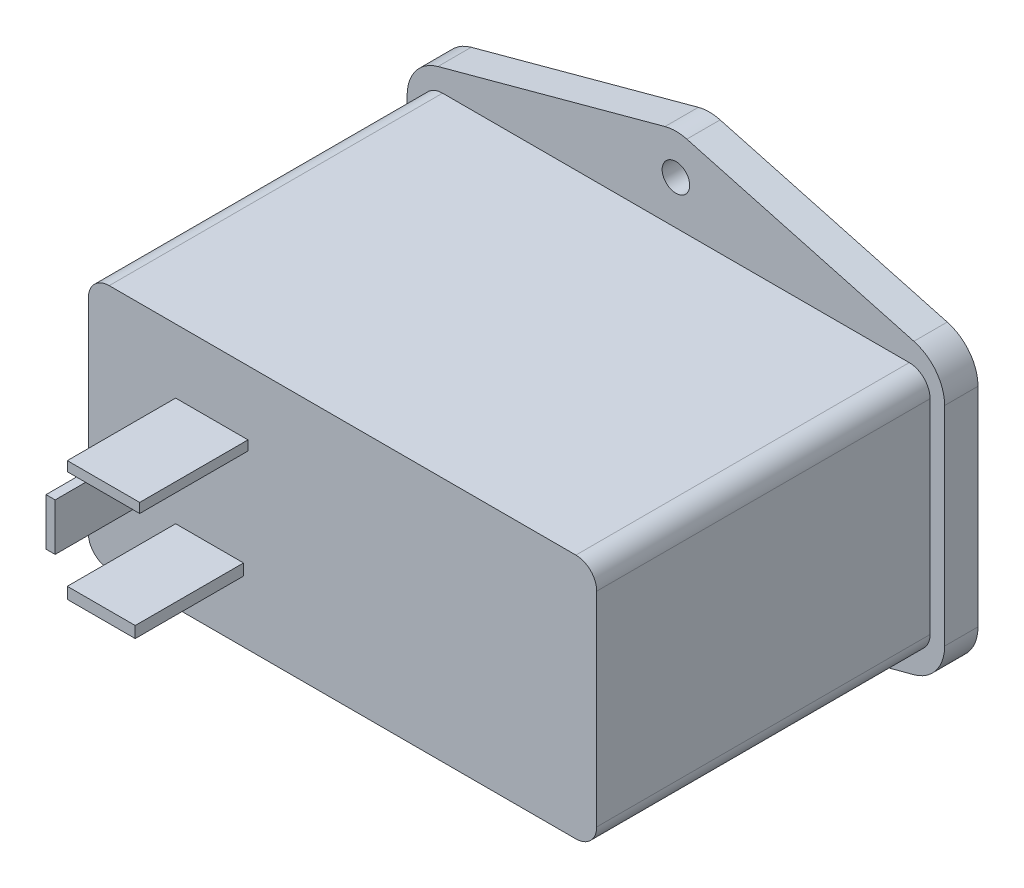
from build123d import *

# Parameters (mm, degrees)
BOSS_EXTRUDE1_DEPTH = 40
SKETCH2_R           = 1.65
BOSS_EXTRUDE2_DEPTH = 4
SKETCH3_W           = 1.094631416
SKETCH3_H           = 5.669527591
SKETCH3_W_2         = 8.149744195
SKETCH3_H_2         = 1.362465731
SKETCH3_W_3         = 8.685881664
SKETCH3_H_3         = 1.155421961
BOSS_EXTRUDE3_DEPTH = 13


with BuildPart() as part:
    # Sketch1 → Boss-Extrude1 (new body)
    with BuildSketch(Plane.XY):
        with BuildLine():
            Line((2.5, 0), (58.5, 0))
            ThreePointArc((58.5, 0), (60.267766953, 0.732233047), (61, 2.5))
            Line((61, 2.5), (61, 27))
            ThreePointArc((61, 27), (60.267766953, 28.767766953), (58.5, 29.5))
            Line((58.5, 29.5), (2.5, 29.5))
            ThreePointArc((2.5, 29.5), (0.732233047, 28.767766953), (0, 27))
            Line((0, 27), (0, 2.5))
            ThreePointArc((0, 2.5), (0.732233047, 0.732233047), (2.5, 0))
        make_face()
    extrude(amount=BOSS_EXTRUDE1_DEPTH)

    # Sketch2 → Boss-Extrude2 (add)
    with BuildSketch(Plane(origin=(0, 0, 0), x_dir=(-1, 0, 0), z_dir=(0, 0, -1))):
        with BuildLine():
            Line((-29.192164894, 39.379309675), (-1.942164894, 31.994508834))
            ThreePointArc((-1.942164894, 31.994508834), (0.721094026, 30.206741606), (1.75, 27.168582256))
            Line((1.75, 27.168582256), (1.75, 2.168582256))
            ThreePointArc((1.75, 2.168582256), (0.71380719, -0.879077922), (-1.965293024, -2.663552674))
            Line((-1.965293024, -2.663552674), (-29.215293024, -9.908438343))
            ThreePointArc((-29.215293024, -9.908438343), (-30.5, -10.076303412), (-31.784706976, -9.908438343))
            Line((-31.784706976, -9.908438343), (-59.034706976, -2.663552674))
            ThreePointArc((-59.034706976, -2.663552674), (-61.71380719, -0.879077922), (-62.75, 2.168582256))
            Line((-62.75, 2.168582256), (-62.75, 27.168582256))
            ThreePointArc((-62.75, 27.168582256), (-61.721094026, 30.206741606), (-59.057835106, 31.994508834))
            Line((-59.057835106, 31.994508834), (-31.807835106, 39.379309675))
            ThreePointArc((-31.807835106, 39.379309675), (-30.5, 39.553383097), (-29.192164894, 39.379309675))
        make_face()
        with Locations((-30.5, 34.75)):
            Circle(SKETCH2_R, mode=Mode.SUBTRACT)
        with Locations((-30.5, -5.076303412)):
            Circle(SKETCH2_R, mode=Mode.SUBTRACT)
    extrude(amount=BOSS_EXTRUDE2_DEPTH)

    # Sketch3 → Boss-Extrude3 (add)
    with BuildSketch(Plane.XY.offset(40)):
        with Locations((8.461320631, 14.1528159)):
            Rectangle(SKETCH3_W, SKETCH3_H)
        with Locations((14.54463445, 8.060284138)):
            Rectangle(SKETCH3_W_2, SKETCH3_H_2)
        with Locations((14.812703184, 21.223135875)):
            Rectangle(SKETCH3_W_3, SKETCH3_H_3)
    extrude(amount=BOSS_EXTRUDE3_DEPTH)


solid = part.part
